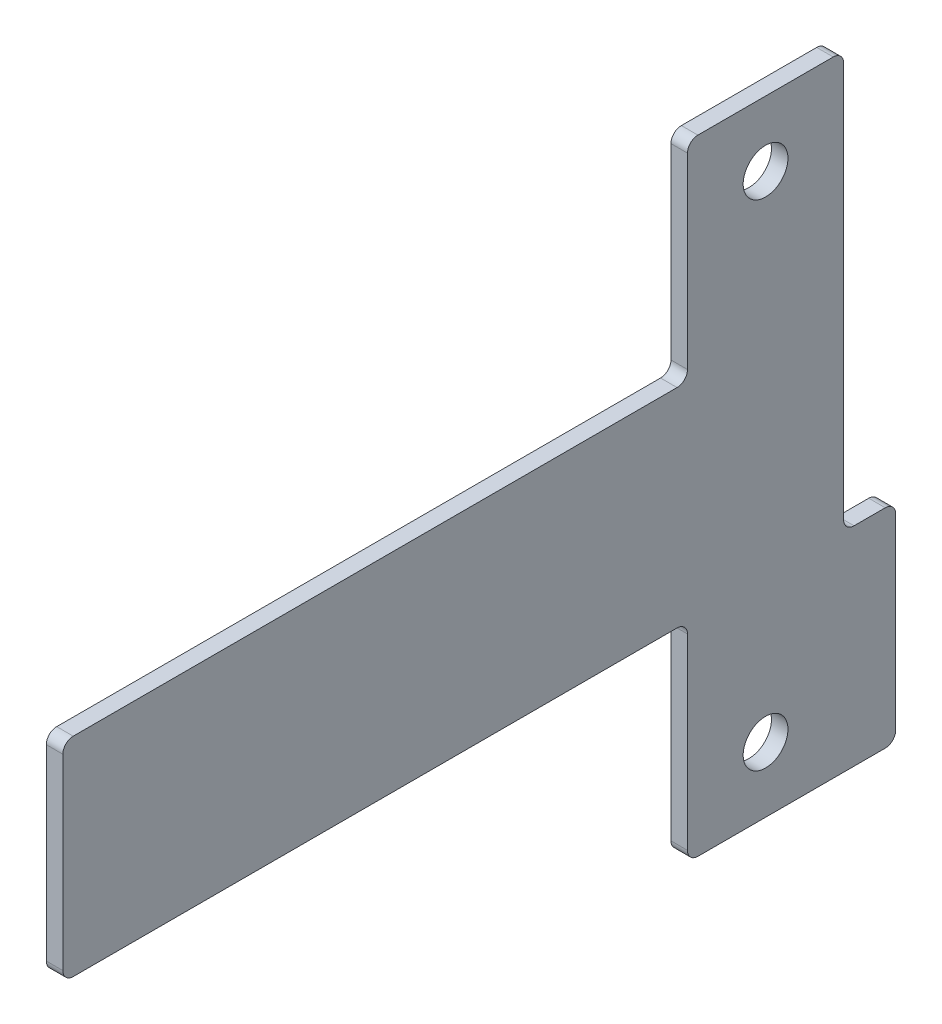
from build123d import *

# Parameters (mm, degrees)
SKETCH1_R           = 2.15
BOSS_EXTRUDE1_DEPTH = 1.5875
FILLET1_R           = 1


with BuildPart() as part:
    # Sketch1 → Boss-Extrude1 (new body)
    with BuildSketch(Plane(origin=(0, 0, 0), x_dir=(0, 0, -1), z_dir=(1, 0, 0))):
        Polygon((-7.5, 30), (7.5, 30), (7.5, -10), (12.5, -10), (12.5, -30), (7.5, -30), (-7.5, -30), (-7.5, -10), (-67.5, -10), (-67.5, 10), (-7.5, 10), align=None)
        with Locations((0, 23.75)):
            Circle(SKETCH1_R, mode=Mode.SUBTRACT)
        with Locations((0, -23.75)):
            Circle(SKETCH1_R, mode=Mode.SUBTRACT)
    extrude(amount=BOSS_EXTRUDE1_DEPTH)

    # Fillet1
    fillet1_edges = [part.edges().sort_by_distance(p)[0] for p in [
        (0.79375, 30, 7.5),
        (0.79375, 30, -7.5),
        (0.79375, -10, -7.5),
        (0.79375, -10, -12.5),
        (0.79375, -30, -12.5),
        (0.79375, -30, 7.5),
        (0.79375, -10, 7.5),
        (0.79375, -10, 67.5),
        (0.79375, 10, 67.5),
        (0.79375, 10, 7.5),
    ]]
    fillet(fillet1_edges, radius=FILLET1_R)


solid = part.part
